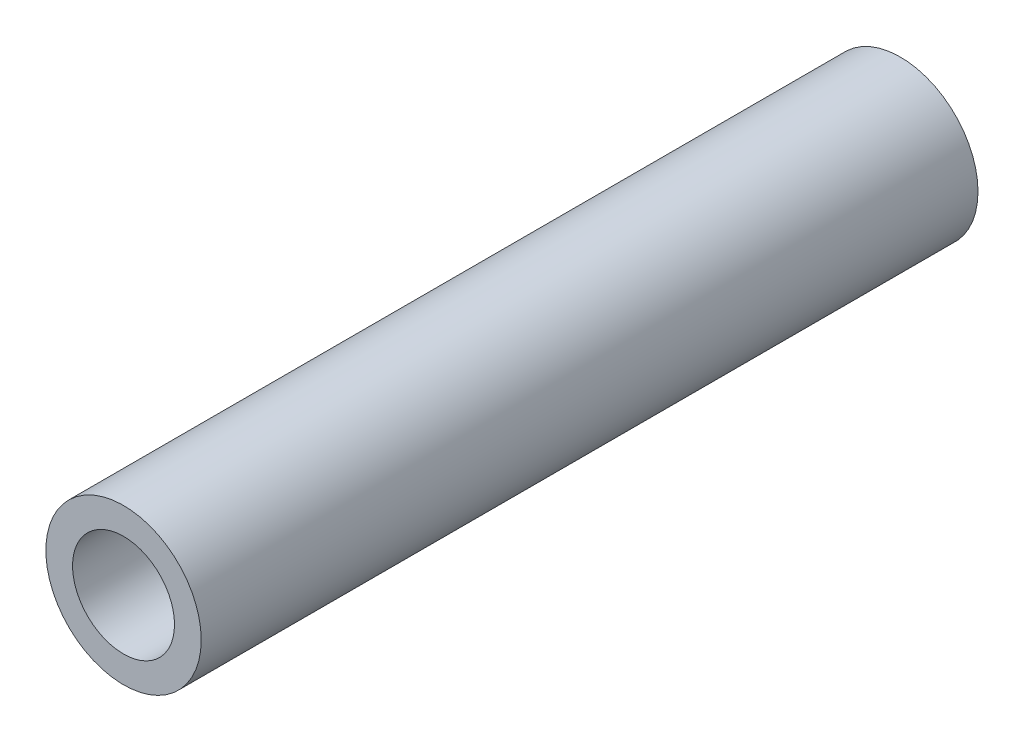
from build123d import *

# Parameters (mm, degrees)
SKETCH1_R           = 12.7
SKETCH1_R_2         = 8.33374
BOSS_EXTRUDE1_DEPTH = 127


with BuildPart() as part:
    # Sketch1 → Boss-Extrude1 (new body)
    with BuildSketch(Plane.XY):
        Circle(SKETCH1_R)
        Circle(SKETCH1_R_2, mode=Mode.SUBTRACT)
    extrude(amount=BOSS_EXTRUDE1_DEPTH)


solid = part.part
